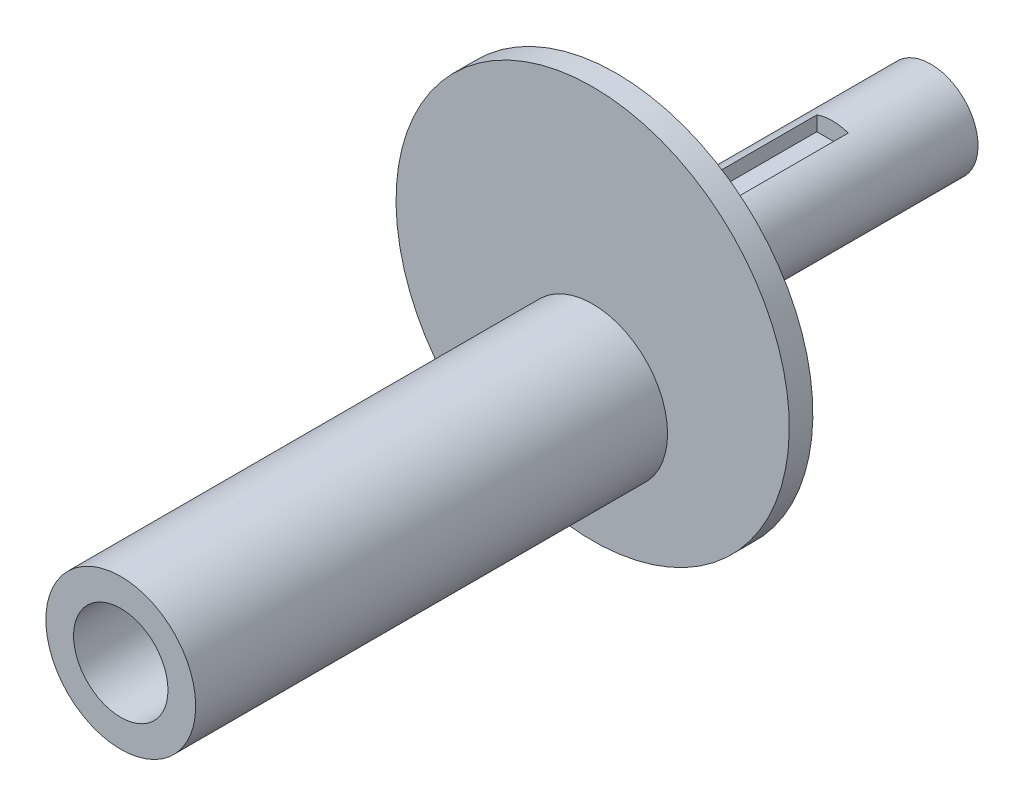
from build123d import *

# Parameters (mm, degrees)
SKETCH2_R           = 9.525
SKETCH2_R_2         = 6
BOSS_EXTRUDE1_DEPTH = 60
CUT_EXTRUDE1_START  = 2.5
SKETCH5_W           = 4
SKETCH5_H           = 4
CUT_EXTRUDE1_DEPTH  = 25


with BuildPart() as part:
    # Sketch1 → Revolve1 (revolve)
    with BuildSketch(Plane(origin=(0, 0, 0), x_dir=(0, 0, -1), z_dir=(1, 0, 0))):
        Polygon((0, 6), (0, 25), (-3, 25), (-3, 0), (27.090074414, 0), (28, 2.5), (40, 2.5), (40, 6), align=None)
    revolve(axis=Axis((0, 0, -27.090074414), (0, 0, 1)))

    # Sketch2 → Boss-Extrude1 (add)
    with BuildSketch(Plane.XY.offset(3)):
        with Locations((0, -8.4375)):
            Circle(SKETCH2_R)
        with Locations((0, -8.4375)):
            Circle(SKETCH2_R_2, mode=Mode.SUBTRACT)
    extrude(amount=BOSS_EXTRUDE1_DEPTH)

    # Sketch5 → Cut-Extrude1 (cut)
    with BuildSketch(Plane(origin=(0, 0, 0), x_dir=(-1, 0, 0), z_dir=(0, 0, -1)).offset(CUT_EXTRUDE1_START)):
        with Locations((0, -5.8)):
            Rectangle(SKETCH5_W, SKETCH5_H)
    cut_extrude1 = extrude(amount=CUT_EXTRUDE1_DEPTH, mode=Mode.SUBTRACT)

    # Mirror1: Cut-Extrude1 across plane
    add(cut_extrude1.mirror(Plane.ZX), mode=Mode.SUBTRACT)


solid = part.part
